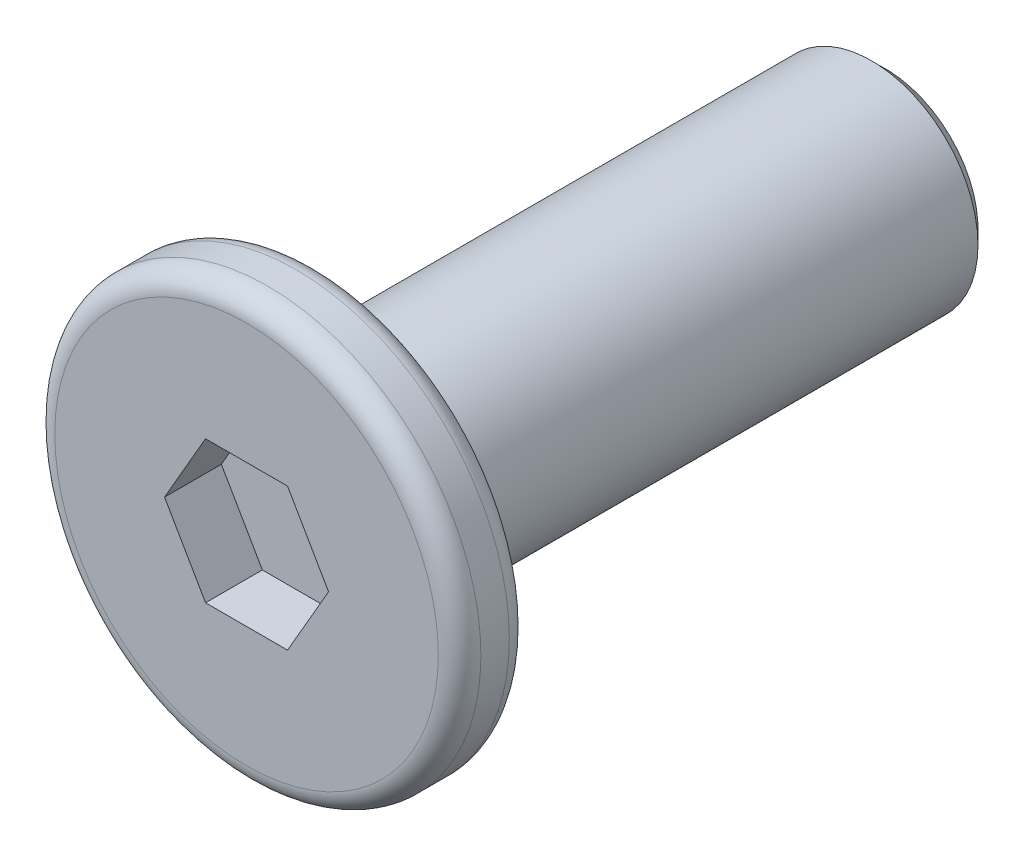
from build123d import *

# Parameters (mm, degrees)
SKETCH_1_R          = 3
EXTRUDE_1_DEPTH     = 0.5
SKETCH_2_R          = 1.5
EXTRUDE_2_DEPTH     = 8
CHAMFER_1_SIZE      = 0.2
CUT_EXTRUDE_1_DEPTH = 0.8
FILLET_2_R          = 0.3


with BuildPart() as part:
    # 草图1 → 凸台-拉伸1 (new body, symmetric)
    with BuildSketch(Plane.XY):
        Circle(SKETCH_1_R)
    extrude(amount=EXTRUDE_1_DEPTH, both=True)

    # 草图2 → 凸台-拉伸2 (add)
    with BuildSketch(Plane(origin=(0, 0, -0.5), x_dir=(-1, 0, 0), z_dir=(0, 0, -1))):
        Circle(SKETCH_2_R)
    extrude(amount=EXTRUDE_2_DEPTH)

    # 倒角1
    chamfer_1_edges = [part.edges().sort_by_distance(p)[0] for p in [
        (1.5, 0, -8.5),
    ]]
    chamfer(chamfer_1_edges, length=CHAMFER_1_SIZE)

    # 草图3 → 切除-拉伸1 (cut)
    with BuildSketch(Plane.XY.offset(0.5)):
        Polygon((1.154700538, 0), (0.577350269, 1), (-0.577350269, 1), (-1.154700538, 0), (-0.577350269, -1), (0.577350269, -1), align=None)
    extrude(amount=-CUT_EXTRUDE_1_DEPTH, mode=Mode.SUBTRACT)

    # 圆角2
    fillet_2_edges = [part.edges().sort_by_distance(p)[0] for p in [
        (-3, 0, -0.5),
        (-3, 0, 0.5),
    ]]
    fillet(fillet_2_edges, radius=FILLET_2_R)


solid = part.part
